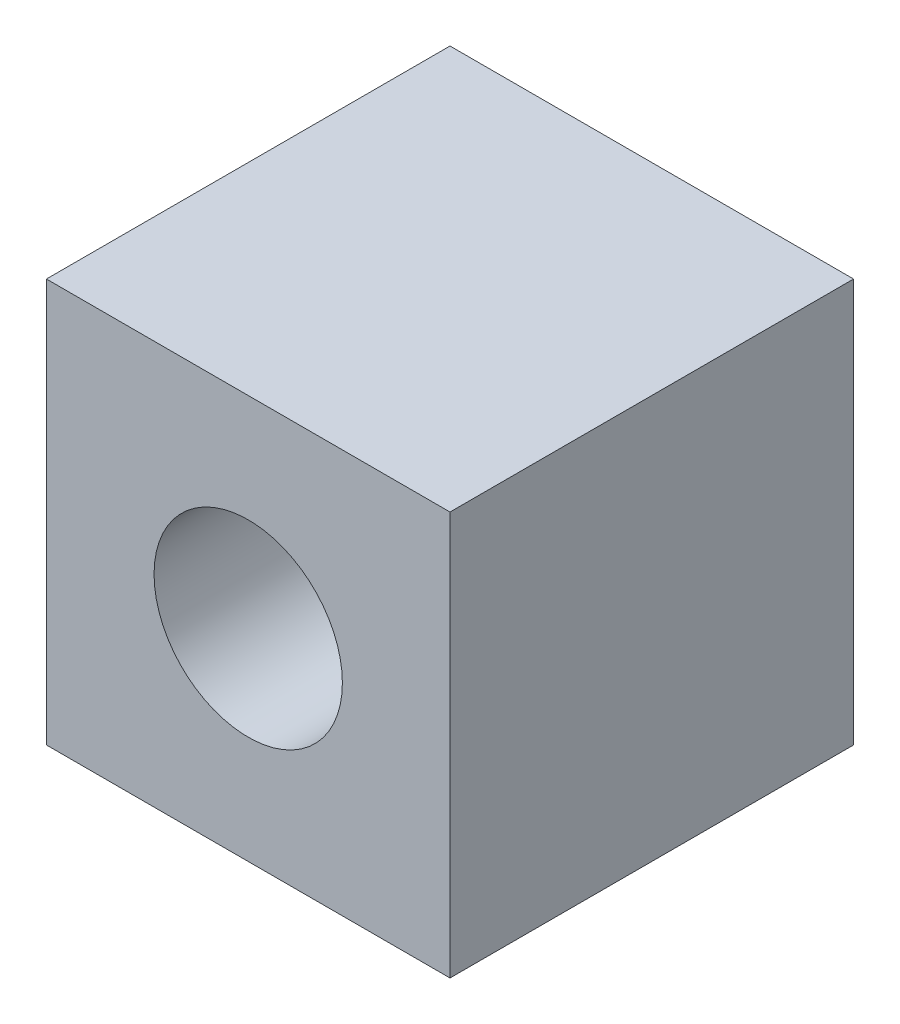
from build123d import *

# Parameters (mm, degrees)
SKETCH_1_W          = 6
SKETCH_1_H          = 6
EXTRUDE_1_DEPTH     = 6
SKETCH_2_R          = 1.4
CUT_EXTRUDE_1_DEPTH = 7


with BuildPart() as part:
    # ｽｹｯﾁ1 → ﾎﾞｽ - 押し出し1 (new body)
    with BuildSketch(Plane.XY):
        with Locations((0.221154353, -0.1069869)):
            Rectangle(SKETCH_1_W, SKETCH_1_H)
    extrude(amount=EXTRUDE_1_DEPTH)

    # ｽｹｯﾁ2 → ｶｯﾄ - 押し出し1 (cut, through all)
    with BuildSketch(Plane.XY.offset(6)):
        with Locations((0.221154353, -0.1069869)):
            Circle(SKETCH_2_R)
    extrude(amount=-CUT_EXTRUDE_1_DEPTH, mode=Mode.SUBTRACT)


solid = part.part
